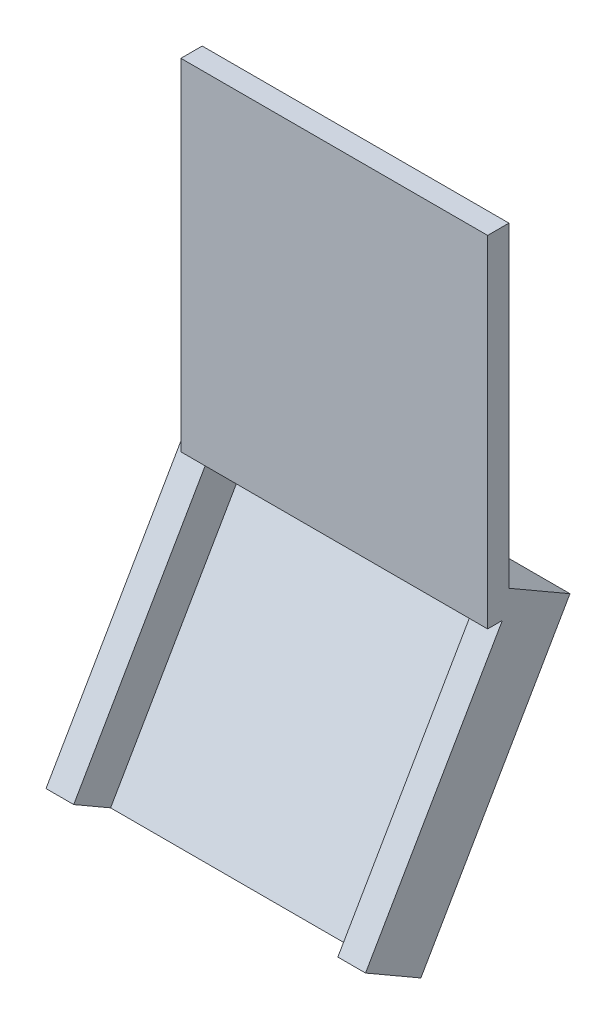
from build123d import *

# Parameters (mm, degrees)
SKIZZE1_W                       = 14.4
SKIZZE1_H                       = 16
AUFSATZ_LINEAR_AUSTRAGEN1_DEPTH = 1
AUFSATZ_LINEAR_AUSTRAGEN4_DEPTH = 15
SKIZZE9_W                       = 1.3
SKIZZE9_H                       = 13
AUFSATZ_LINEAR_AUSTRAGEN5_DEPTH = 2


with BuildPart() as part:
    # Skizze1 → Aufsatz-Linear austragen1 (new body)
    with BuildSketch(Plane.XY):
        with Locations((7.2, 8)):
            Rectangle(SKIZZE1_W, SKIZZE1_H)
    extrude(amount=AUFSATZ_LINEAR_AUSTRAGEN1_DEPTH)

    # Skizze4 → Aufsatz-Linear austragen4 (add)
    with BuildSketch(Plane(origin=(14.4, 0, 0), x_dir=(0, 0, -1), z_dir=(1, 0, 0))):
        Polygon((0, 1.154700538), (0, 0), (1.5, -0.866025404), (-5, -12.124355653), (-4.133974596, -12.624355653), (2.866025404, -0.5), align=None)
    extrude(amount=-AUFSATZ_LINEAR_AUSTRAGEN4_DEPTH)

    # Skizze9 → Aufsatz-Linear austragen5 (add)
    with BuildSketch(Plane(origin=(0, -0.866025404, -1.5), x_dir=(1, 0, 0), z_dir=(0, 0.49999999999999484, 0.8660254037844418))):
        with Locations((13.75, -6.5)):
            Rectangle(SKIZZE9_W, SKIZZE9_H)
        with Locations((0.05, -6.5)):
            Rectangle(SKIZZE9_W, SKIZZE9_H)
    extrude(amount=AUFSATZ_LINEAR_AUSTRAGEN5_DEPTH)


solid = part.part
